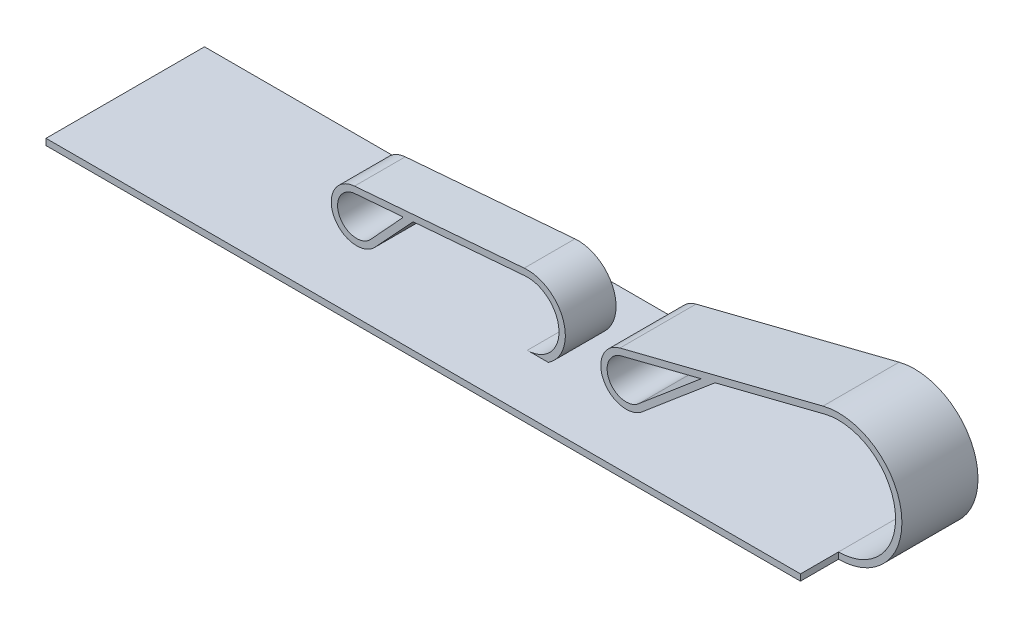
from build123d import *

# Parameters (mm, degrees)
BOSS_EXTRUDE1_START = 8
BOSS_EXTRUDE1_DEPTH = 8
BOSS_EXTRUDE2_START = 7
BOSS_EXTRUDE2_DEPTH = 12
BOSS_EXTRUDE3_DEPTH = 25


with BuildPart() as part:
    # Sketch1 → Boss-Extrude1 (new body)
    with BuildSketch(Plane.XY.offset(BOSS_EXTRUDE1_START)):
        with BuildLine():
            ThreePointArc((74.83730752, 9.983544534), (80.238511438, 5.202826688), (75.242626998, 0))
            Line((75.242626998, 0), (78.559251789, 0))
            ThreePointArc((78.559251789, 0), (80.9122, 6.963655259), (74.756243624, 10.980253441))
            Line((74.756243624, 10.980253441), (47.994339706, 8.803665899))
            ThreePointArc((47.994339706, 8.803665899), (44.723252789, 3.063686722), (51.260118774, 2.106214182))
            Line((51.260118774, 2.106214182), (57.235944241, 8.551998103))
            Line((57.235944241, 8.551998103), (74.83730752, 9.983544534))
        make_face()
        with BuildLine():
            Line((55.553573418, 8.241091684), (50.524737903, 2.783868204))
            ThreePointArc((50.524737903, 2.783868204), (45.622088414, 3.501972609), (48.075403602, 7.806956992))
            Line((48.075403602, 7.806956992), (55.471928941, 8.408527977))
            ThreePointArc((55.471928941, 8.408527977), (55.569918893, 8.352685675), (55.553573418, 8.241091684))
        make_face(mode=Mode.SUBTRACT)
    extrude(amount=BOSS_EXTRUDE1_DEPTH)



with BuildPart() as body_2:
    # Sketch1_5 → Boss-Extrude2 (new body)
    with BuildSketch(Plane.XY.offset(BOSS_EXTRUDE2_START)):
        with BuildLine():
            Line((127.329435135, 0), (127.329435135, -1))
            ThreePointArc((127.329435135, -1), (137.253233755, 10.232161094), (124.883891422, 18.696355808))
            Line((124.883891422, 18.696355808), (92.855908874, 10.61849306))
            ThreePointArc((92.855908874, 10.61849306), (90.346819157, 4.780693613), (96.637825713, 3.88701016))
            Line((96.637825713, 3.88701016), (107.85561912, 13.370294626))
            Line((107.85561912, 13.370294626), (125.128445793, 17.726720227))
            ThreePointArc((125.128445793, 17.726720227), (136.260853893, 10.108944985), (127.329435135, 0))
        make_face()
        with BuildLine():
            Line((105.648911717, 12.813735076), (95.936900874, 4.600245304))
            ThreePointArc((95.936900874, 4.600245304), (91.218645958, 5.270507894), (93.100463246, 9.648857479))
            Line((93.100463246, 9.648857479), (105.648911717, 12.813735076))
        make_face(mode=Mode.SUBTRACT)
    extrude(amount=BOSS_EXTRUDE2_DEPTH)


with BuildPart() as part_1:
    add(part.part)

    add(body_2.part)  # Boss-Extrude3 merges body 2
    # Sketch1_6 → Boss-Extrude3 (add)
    with BuildSketch(Plane.XY):
        Polygon((75.242626998, 0), (8.329435135, 0), (8.329435135, -1), (127.329435135, -1), (127.329435135, 0), (78.559251789, 0), align=None)
    extrude(amount=BOSS_EXTRUDE3_DEPTH)


solid = part_1.part
